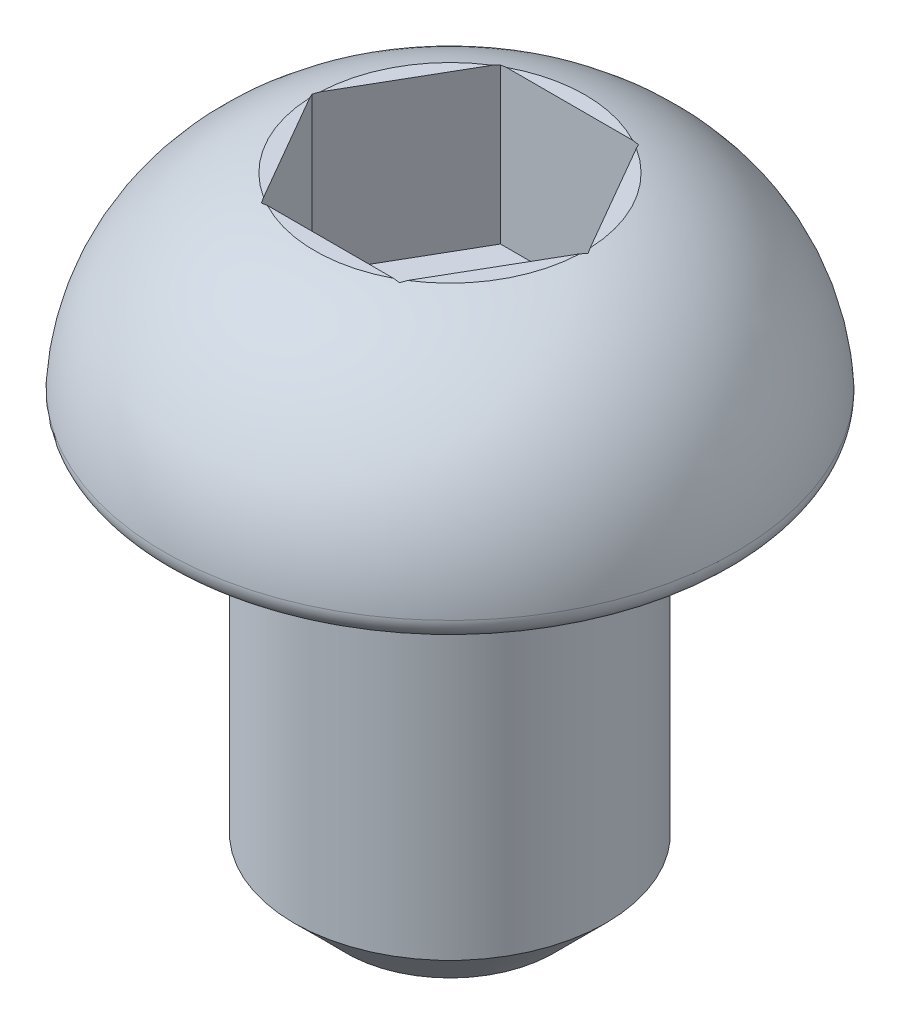
from build123d import *

# Parameters (mm, degrees)
FILLET_1_R          = 0.2
CUT_EXTRUDE_1_DEPTH = 1.5
SKETCH_3_R          = 1.5
EXTRUDE_1_DEPTH     = 4
CHAMFER_1_SIZE      = 0.5


with BuildPart() as part:
    # 草图1 → 旋转1 (revolve)
    with BuildSketch(Plane.XY):
        with BuildLine():
            Line((0, 0), (0, 2))
            Line((0, 2), (1.3, 2))
            ThreePointArc((1.3, 2), (2.370691821, 1.250626571), (2.75, 0))
            Line((2.75, 0), (0, 0))
        make_face()
    revolve(axis=Axis((0, 0, 0), (0, 1, 0)))

    # 圆角1
    fillet_1_edges = [part.edges().sort_by_distance(p)[0] for p in [
        (-2.75, 0, 0),
    ]]
    fillet(fillet_1_edges, radius=FILLET_1_R)

    # 草图2 → 切除-拉伸1 (cut)
    with BuildSketch(Plane(origin=(0, 2, 0), x_dir=(1, 0, 0), z_dir=(0, 1, 0))):
        Polygon((1.327905619, 0), (0.66395281, 1.15), (-0.66395281, 1.15), (-1.327905619, 0), (-0.66395281, -1.15), (0.66395281, -1.15), align=None)
    extrude(amount=-CUT_EXTRUDE_1_DEPTH, mode=Mode.SUBTRACT)

    # 草图3 → 凸台-拉伸1 (add)
    with BuildSketch(Plane.XZ):
        Circle(SKETCH_3_R)
    extrude(amount=EXTRUDE_1_DEPTH)

    # 倒角1
    chamfer_1_edges = [part.edges().sort_by_distance(p)[0] for p in [
        (-1.5, -4, 0),
    ]]
    chamfer(chamfer_1_edges, length=CHAMFER_1_SIZE)


solid = part.part
